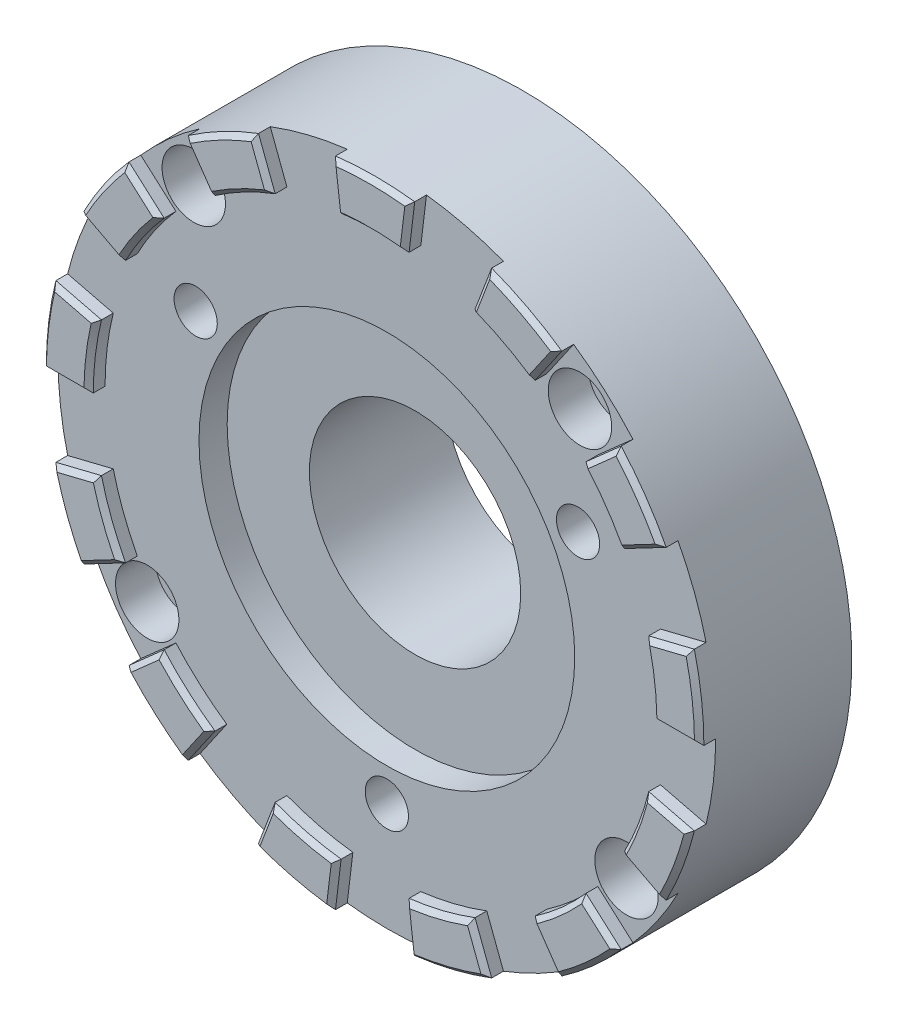
from build123d import *

# Parameters (mm, degrees)
SKETCH_1_R          = 70
EXTRUDE_1_DEPTH     = 35
EXTRUDE_2_DEPTH     = 3.5
CHAMFER_1_SIZE      = 1
SKETCH_3_R          = 40
CUT_EXTRUDE_1_DEPTH = 6
SKETCH_5_R          = 4.6
CUT_EXTRUDE_2_DEPTH = 49
SKETCH_6_R          = 70
SKETCH_6_R_2        = 55
CUT_EXTRUDE_3_DEPTH = 6
SKETCH_7_R          = 6.75
CUT_EXTRUDE_4_DEPTH = 8.5
SKETCH_8_R          = 4
CUT_EXTRUDE_5_DEPTH = 40.5
SKETCH_9_R          = 22.5
CUT_EXTRUDE_6_DEPTH = 49.5


with BuildPart() as part:
    # 草图1 → 凸台-拉伸1 (new body)
    with BuildSketch(Plane.XY):
        Circle(SKETCH_1_R)
    extrude(amount=EXTRUDE_1_DEPTH)

    # 草图2 → 凸台-拉伸2 (add)
    with BuildSketch(Plane.XY.offset(35)):
        with BuildLine():
            Line((60, 0), (70, 0))
            ThreePointArc((70, 0), (69.489621187, 8.437567618), (67.96592722, 16.7520965))
            Line((67.96592722, 16.7520965), (58.256509046, 14.358939857))
            ThreePointArc((58.256509046, 14.358939857), (59.562532446, 7.232200815), (60, 0))
        make_face()
        with BuildLine():
            Line((53.127361539, 27.883390323), (61.981921796, 32.530622043))
            ThreePointArc((61.981921796, 32.530622043), (57.608870613, 39.764532271), (52.395752372, 46.418586077))
            Line((52.395752372, 46.418586077), (44.91064489, 39.787359494))
            ThreePointArc((44.91064489, 39.787359494), (49.379031954, 34.083884804), (53.127361539, 27.883390323))
        make_face()
        with BuildLine():
            Line((34.083884804, 49.379031954), (39.764532271, 57.608870613))
            ThreePointArc((39.764532271, 57.608870613), (32.530622043, 61.981921796), (24.822342093, 65.451136988))
            Line((24.822342093, 65.451136988), (21.276293223, 56.100974561))
            ThreePointArc((21.276293223, 56.100974561), (27.883390323, 53.127361539), (34.083884804, 49.379031954))
        make_face()
        with BuildLine():
            Line((7.232200815, 59.562532446), (8.437567618, 69.489621187))
            ThreePointArc((8.437567618, 69.489621187), (0, 70), (-8.437567618, 69.489621187))
            Line((-8.437567618, 69.489621187), (-7.232200815, 59.562532446))
            ThreePointArc((-7.232200815, 59.562532446), (0, 60), (7.232200815, 59.562532446))
        make_face()
        with BuildLine():
            Line((-21.276293223, 56.100974561), (-24.822342093, 65.451136988))
            ThreePointArc((-24.822342093, 65.451136988), (-32.530622043, 61.981921796), (-39.764532271, 57.608870613))
            Line((-39.764532271, 57.608870613), (-34.083884804, 49.379031954))
            ThreePointArc((-34.083884804, 49.379031954), (-27.883390323, 53.127361539), (-21.276293223, 56.100974561))
        make_face()
        with BuildLine():
            Line((-44.91064489, 39.787359494), (-52.395752372, 46.418586077))
            ThreePointArc((-52.395752372, 46.418586077), (-57.608870613, 39.764532271), (-61.981921796, 32.530622043))
            Line((-61.981921796, 32.530622043), (-53.127361539, 27.883390323))
            ThreePointArc((-53.127361539, 27.883390323), (-49.379031954, 34.083884804), (-44.91064489, 39.787359494))
        make_face()
        with BuildLine():
            Line((-58.256509046, 14.358939857), (-67.96592722, 16.7520965))
            ThreePointArc((-67.96592722, 16.7520965), (-69.489621187, 8.437567618), (-70, 0))
            Line((-70, 0), (-60, 0))
            ThreePointArc((-60, 0), (-59.562532446, 7.232200815), (-58.256509046, 14.358939857))
        make_face()
        with BuildLine():
            Line((-58.256509046, -14.358939857), (-67.96592722, -16.7520965))
            ThreePointArc((-67.96592722, -16.7520965), (-65.451136988, -24.822342093), (-61.981921796, -32.530622043))
            Line((-61.981921796, -32.530622043), (-53.127361539, -27.883390323))
            ThreePointArc((-53.127361539, -27.883390323), (-56.100974561, -21.276293223), (-58.256509046, -14.358939857))
        make_face()
        with BuildLine():
            Line((-44.91064489, -39.787359494), (-52.395752372, -46.418586077))
            ThreePointArc((-52.395752372, -46.418586077), (-46.418586077, -52.395752372), (-39.764532271, -57.608870613))
            Line((-39.764532271, -57.608870613), (-34.083884804, -49.379031954))
            ThreePointArc((-34.083884804, -49.379031954), (-39.787359494, -44.91064489), (-44.91064489, -39.787359494))
        make_face()
        with BuildLine():
            Line((-21.276293223, -56.100974561), (-24.822342093, -65.451136988))
            ThreePointArc((-24.822342093, -65.451136988), (-16.7520965, -67.96592722), (-8.437567618, -69.489621187))
            Line((-8.437567618, -69.489621187), (-7.232200815, -59.562532446))
            ThreePointArc((-7.232200815, -59.562532446), (-14.358939857, -58.256509046), (-21.276293223, -56.100974561))
        make_face()
        with BuildLine():
            Line((7.232200815, -59.562532446), (8.437567618, -69.489621187))
            ThreePointArc((8.437567618, -69.489621187), (16.7520965, -67.96592722), (24.822342093, -65.451136988))
            Line((24.822342093, -65.451136988), (21.276293223, -56.100974561))
            ThreePointArc((21.276293223, -56.100974561), (14.358939857, -58.256509046), (7.232200815, -59.562532446))
        make_face()
        with BuildLine():
            Line((34.083884804, -49.379031954), (39.764532271, -57.608870613))
            ThreePointArc((39.764532271, -57.608870613), (46.418586077, -52.395752372), (52.395752372, -46.418586077))
            Line((52.395752372, -46.418586077), (44.91064489, -39.787359494))
            ThreePointArc((44.91064489, -39.787359494), (39.787359494, -44.91064489), (34.083884804, -49.379031954))
        make_face()
        with BuildLine():
            Line((53.127361539, -27.883390323), (61.981921796, -32.530622043))
            ThreePointArc((61.981921796, -32.530622043), (65.451136988, -24.822342093), (67.96592722, -16.7520965))
            Line((67.96592722, -16.7520965), (58.256509046, -14.358939857))
            ThreePointArc((58.256509046, -14.358939857), (56.100974561, -21.276293223), (53.127361539, -27.883390323))
        make_face()
    extrude(amount=EXTRUDE_2_DEPTH)

    # 倒角1
    chamfer_1_edges = [part.edges().sort_by_distance(p)[0] for p in [
        (63.111218133, 15.555518179, 38.5),
        (69.489621187, 8.437567618, 38.5),
        (65, 0, 38.5),
        (59.562532446, 7.232200815, 38.5),
        (63.111218133, -15.555518179, 38.5),
        (65.451136988, -24.822342093, 38.5),
        (57.554641667, -30.207006183, 38.5),
        (56.100974561, -21.276293223, 38.5),
        (48.653198631, -43.102972786, 38.5),
        (46.418586077, -52.395752372, 38.5),
        (36.924208538, -53.493951283, 38.5),
        (39.787359494, -44.91064489, 38.5),
        (23.049317658, -60.776055775, 38.5),
        (16.7520965, -67.96592722, 38.5),
        (7.834884217, -64.526076816, 38.5),
        (14.358939857, -58.256509046, 38.5),
        (-7.834884217, -64.526076816, 38.5),
        (-16.7520965, -67.96592722, 38.5),
        (-23.049317658, -60.776055775, 38.5),
        (-14.358939857, -58.256509046, 38.5),
        (-36.924208538, -53.493951283, 38.5),
        (-46.418586077, -52.395752372, 38.5),
        (-48.653198631, -43.102972786, 38.5),
        (-39.787359494, -44.91064489, 38.5),
        (-57.554641667, -30.207006183, 38.5),
        (-65.451136988, -24.822342093, 38.5),
        (-63.111218133, -15.555518179, 38.5),
        (-56.100974561, -21.276293223, 38.5),
        (-65, 0, 38.5),
        (-69.489621187, 8.437567618, 38.5),
        (-63.111218133, 15.555518179, 38.5),
        (-59.562532446, 7.232200815, 38.5),
        (-48.653198631, 43.102972786, 38.5),
        (-49.379031954, 34.083884804, 38.5),
        (-57.554641667, 30.207006183, 38.5),
        (-57.608870613, 39.764532271, 38.5),
        (-23.049317658, 60.776055775, 38.5),
        (-27.883390323, 53.127361539, 38.5),
        (-36.924208538, 53.493951283, 38.5),
        (-32.530622043, 61.981921796, 38.5),
        (7.834884217, 64.526076816, 38.5),
        (0, 60, 38.5),
        (-7.834884217, 64.526076816, 38.5),
        (0, 70, 38.5),
        (36.924208538, 53.493951283, 38.5),
        (27.883390323, 53.127361539, 38.5),
        (23.049317658, 60.776055775, 38.5),
        (32.530622043, 61.981921796, 38.5),
        (57.554641667, 30.207006183, 38.5),
        (49.379031954, 34.083884804, 38.5),
        (48.653198631, 43.102972786, 38.5),
        (57.608870613, 39.764532271, 38.5),
    ]]
    chamfer(chamfer_1_edges, length=CHAMFER_1_SIZE)

    # 草图3 → 切除-拉伸1 (cut)
    with BuildSketch(Plane.XY.offset(35)):
        Circle(SKETCH_3_R)
    extrude(amount=-CUT_EXTRUDE_1_DEPTH, mode=Mode.SUBTRACT)

    # 草图5 → 切除-拉伸2 (cut)
    with BuildSketch(Plane(origin=(0, 0, 0), x_dir=(-1, 0, 0), z_dir=(0, 0, -1))):
        with Locations((-40.703193978, 23.5)):
            Circle(SKETCH_5_R)
        with Locations((40.703193978, 23.5)):
            Circle(SKETCH_5_R)
        with Locations((0, -47)):
            Circle(SKETCH_5_R)
    extrude(amount=-CUT_EXTRUDE_2_DEPTH, mode=Mode.SUBTRACT)

    # 草图6 → 切除-拉伸3 (cut)
    with BuildSketch(Plane(origin=(0, 0, 0), x_dir=(-1, 0, 0), z_dir=(0, 0, -1))):
        Circle(SKETCH_6_R)
        Circle(SKETCH_6_R_2, mode=Mode.SUBTRACT)
    extrude(amount=-CUT_EXTRUDE_3_DEPTH, mode=Mode.SUBTRACT)

    # 草图7 → 切除-拉伸4 (cut)
    with BuildSketch(Plane.XY.offset(35)):
        with Locations((51.024999685, -35.220014297)):
            Circle(SKETCH_7_R)
        with Locations((-51.024999685, -35.220014297)):
            Circle(SKETCH_7_R)
        with Locations((-41.113604811, 46.407666387)):
            Circle(SKETCH_7_R)
        with Locations((41.113604811, 46.407666387)):
            Circle(SKETCH_7_R)
    extrude(amount=-CUT_EXTRUDE_4_DEPTH, mode=Mode.SUBTRACT)

    # 草图8 → 切除-拉伸5 (cut)
    with BuildSketch(Plane.XY.offset(26.5)):
        with Locations((41.113604811, 46.407666387)):
            Circle(SKETCH_8_R)
        with Locations((51.024999685, -35.220014297)):
            Circle(SKETCH_8_R)
        with Locations((-51.024999685, -35.220014297)):
            Circle(SKETCH_8_R)
        with Locations((-41.113604811, 46.407666387)):
            Circle(SKETCH_8_R)
    extrude(amount=-CUT_EXTRUDE_5_DEPTH, mode=Mode.SUBTRACT)

    # 草图9 → 切除-拉伸6 (cut)
    with BuildSketch(Plane.XY.offset(29)):
        Circle(SKETCH_9_R)
    extrude(amount=-CUT_EXTRUDE_6_DEPTH, mode=Mode.SUBTRACT)


solid = part.part
